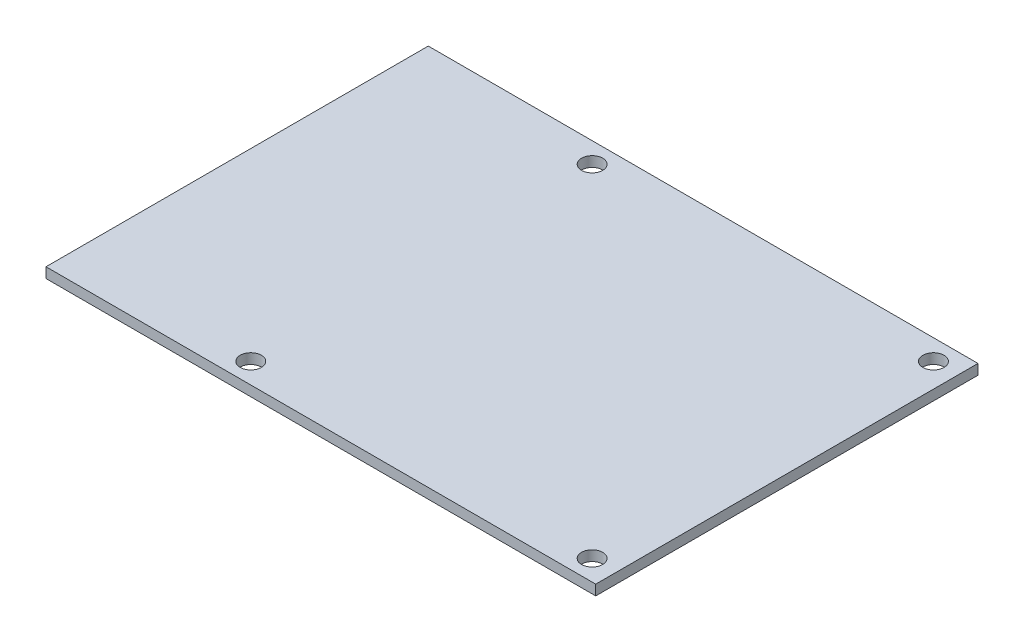
from build123d import *

# Parameters (mm, degrees)
SKETCH_1_W      = 80.527023957
SKETCH_1_H      = 56
SKETCH_1_R      = 1.55
EXTRUDE_1_DEPTH = 1.5


with BuildPart() as part:
    # 草图1 → 凸台-拉伸1 (new body)
    with BuildSketch(Plane(origin=(0, 0, 0), x_dir=(1, 0, 0), z_dir=(0, 1, 0))):
        with Locations((3.736488021, 0)):
            Rectangle(SKETCH_1_W, SKETCH_1_H)
        with Locations((-9.527023957, 25)):
            Circle(SKETCH_1_R, mode=Mode.SUBTRACT)
        with Locations((-9.527023957, -25)):
            Circle(SKETCH_1_R, mode=Mode.SUBTRACT)
        with Locations((40.472976043, -25)):
            Circle(SKETCH_1_R, mode=Mode.SUBTRACT)
        with Locations((40.472976043, 25)):
            Circle(SKETCH_1_R, mode=Mode.SUBTRACT)
    extrude(amount=EXTRUDE_1_DEPTH)


solid = part.part
